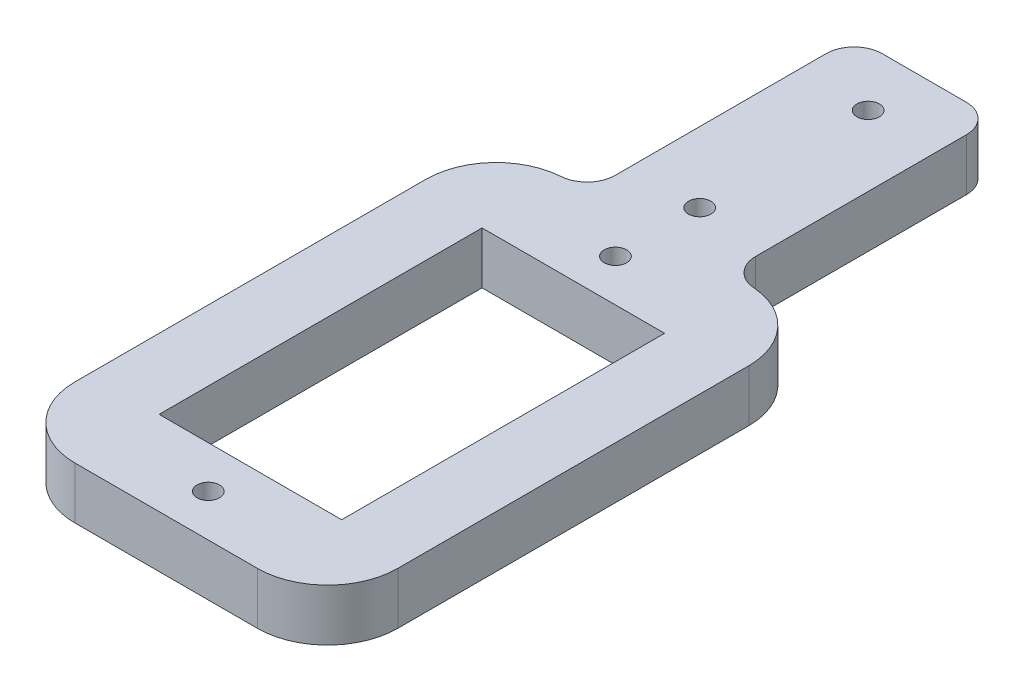
from build123d import *

# Parameters (mm, degrees)
SKETCH2_W           = 23
SKETCH2_H           = 35
SKETCH2_W_2         = 13
SKETCH2_H_2         = 23
BOSS_EXTRUDE1_DEPTH = 3.7
SKETCH3_R           = 0.8
CUT_EXTRUDE1_DEPTH  = 4.7
SKETCH5_W           = 10
SKETCH5_H           = 3.7
BOSS_EXTRUDE3_DEPTH = 19
SKETCH7_R           = 0.8
CUT_EXTRUDE2_DEPTH  = 4.7
FILLET1_R           = 5
FILLET2_R           = 2


with BuildPart() as part:
    # Sketch2 → Boss-Extrude1 (new body)
    with BuildSketch(Plane(origin=(0, 0, 0), x_dir=(1, 0, 0), z_dir=(0, 1, 0))):
        Rectangle(SKETCH2_W, SKETCH2_H)
        Rectangle(SKETCH2_W_2, SKETCH2_H_2, mode=Mode.SUBTRACT)
    extrude(amount=-BOSS_EXTRUDE1_DEPTH)

    # Sketch3 → Cut-Extrude1 (cut, through all)
    with BuildSketch(Plane(origin=(0, 0, 0), x_dir=(1, 0, 0), z_dir=(0, 1, 0))):
        with Locations((0, 14.5)):
            Circle(SKETCH3_R)
        with Locations((0, -14.5)):
            Circle(SKETCH3_R)
    extrude(amount=-CUT_EXTRUDE1_DEPTH, mode=Mode.SUBTRACT)

    # Sketch5 → Boss-Extrude3 (add)
    with BuildSketch(Plane(origin=(0, 0, -17.5), x_dir=(-1, 0, 0), z_dir=(0, 0, -1))):
        with Locations((0, -1.85)):
            Rectangle(SKETCH5_W, SKETCH5_H)
    extrude(amount=BOSS_EXTRUDE3_DEPTH)

    # Sketch7 → Cut-Extrude2 (cut, through all)
    with BuildSketch(Plane(origin=(0, 0, 0), x_dir=(1, 0, 0), z_dir=(0, 1, 0))):
        with Locations((0, 32.5)):
            Circle(SKETCH7_R)
        with Locations((0, 20.5)):
            Circle(SKETCH7_R)
    extrude(amount=-CUT_EXTRUDE2_DEPTH, mode=Mode.SUBTRACT)

    # Fillet1
    fillet1_edges = [part.edges().sort_by_distance(p)[0] for p in [
        (11.5, -1.85, 17.5),
        (-11.5, -1.85, 17.5),
        (-11.5, -1.85, -17.5),
        (11.5, -1.85, -17.5),
    ]]
    fillet(fillet1_edges, radius=FILLET1_R)

    # Fillet2
    fillet2_edges = [part.edges().sort_by_distance(p)[0] for p in [
        (5, -1.85, -17.5),
        (-5, -1.85, -17.5),
        (5, -1.85, -36.5),
        (-5, -1.85, -36.5),
    ]]
    fillet(fillet2_edges, radius=FILLET2_R)


solid = part.part
